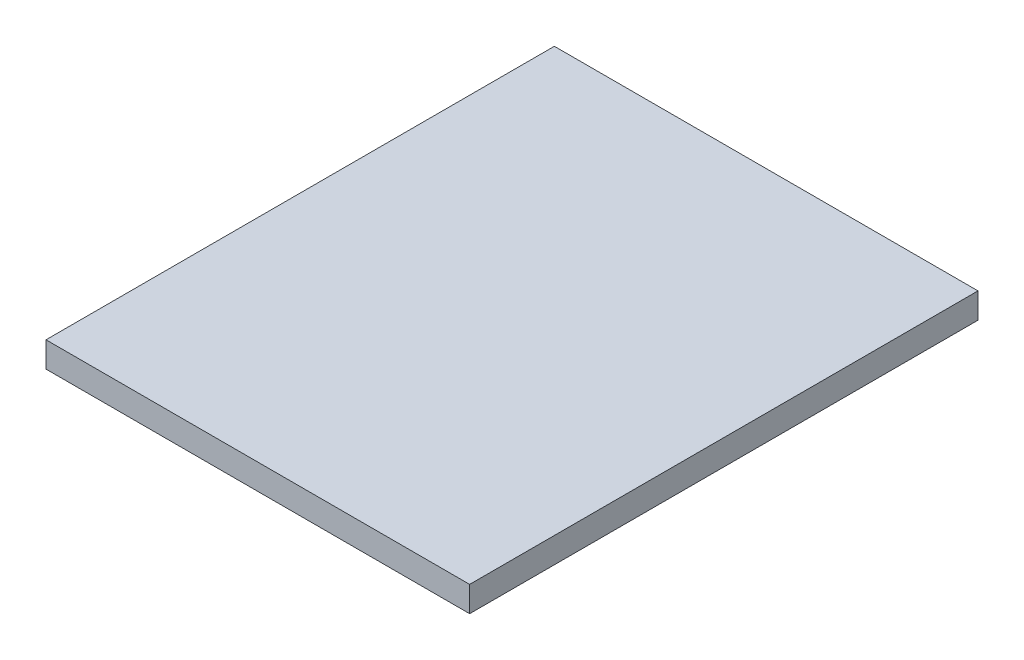
from build123d import *

# Parameters (mm, degrees)
SKETCH1_W           = 100
SKETCH1_H           = 120
BOSS_EXTRUDE1_DEPTH = 6


with BuildPart() as part:
    # Sketch1 → Boss-Extrude1 (new body)
    with BuildSketch(Plane(origin=(0, 0, 0), x_dir=(1, 0, 0), z_dir=(0, 1, 0))):
        with Locations((-40.804597701, 15.574712644)):
            Rectangle(SKETCH1_W, SKETCH1_H)
    extrude(amount=BOSS_EXTRUDE1_DEPTH)


solid = part.part
